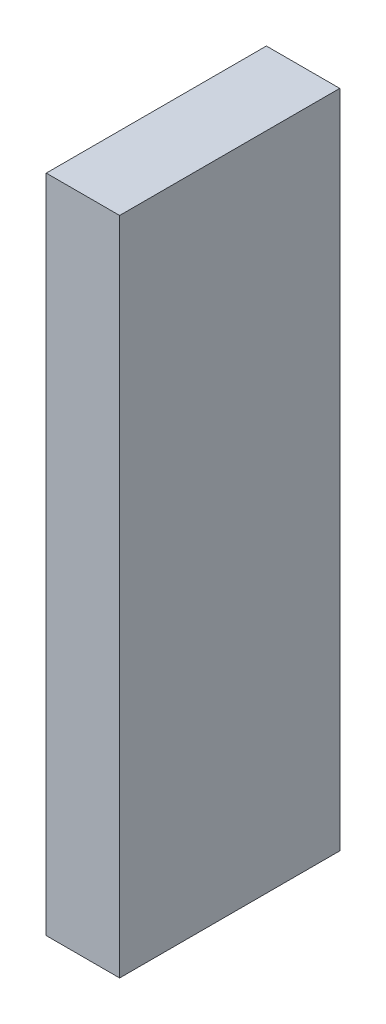
from build123d import *

# Parameters (mm, degrees)
SKETCH1_W           = 9.525
SKETCH1_H           = 28.575
BOSS_EXTRUDE1_DEPTH = 3.175


with BuildPart() as part:
    # Sketch1 → Boss-Extrude1 (new body)
    with BuildSketch(Plane(origin=(0, 0, 0), x_dir=(0, 0, -1), z_dir=(1, 0, 0))):
        Rectangle(SKETCH1_W, SKETCH1_H)
    extrude(amount=BOSS_EXTRUDE1_DEPTH)


solid = part.part
